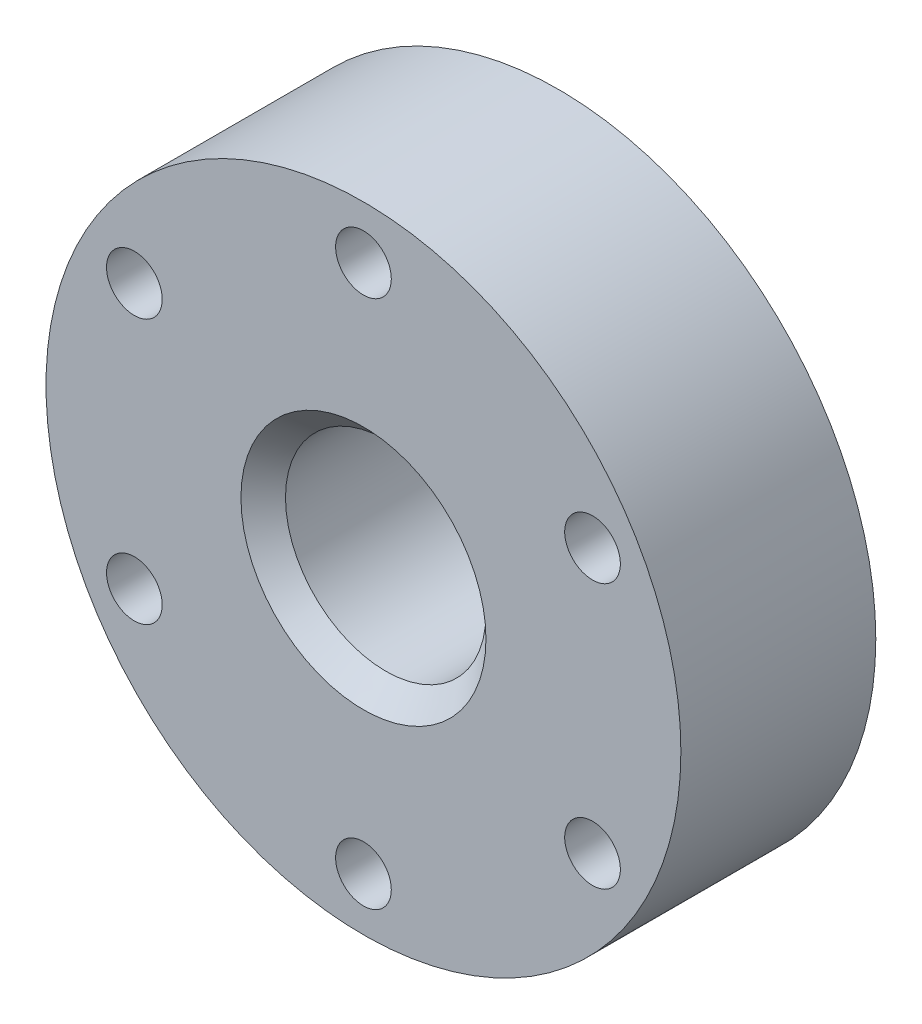
from build123d import *

# Parameters (mm, degrees)
SKETCH1_R           = 28.5
SKETCH1_R_2         = 2.5
BOSS_EXTRUDE1_DEPTH = 17.5
SKETCH2_R           = 9
CUT_EXTRUDE1_DEPTH  = 18.5
CHAMFER1_SIZE       = 2


with BuildPart() as part:
    # Sketch1 → Boss-Extrude1 (new body)
    with BuildSketch(Plane.XY):
        Circle(SKETCH1_R)
        with Locations((0, 23.75)):
            Circle(SKETCH1_R_2, mode=Mode.SUBTRACT)
        with Locations((20.56810334, 11.875)):
            Circle(SKETCH1_R_2, mode=Mode.SUBTRACT)
        with Locations((20.56810334, -11.875)):
            Circle(SKETCH1_R_2, mode=Mode.SUBTRACT)
        with Locations((0, -23.75)):
            Circle(SKETCH1_R_2, mode=Mode.SUBTRACT)
        with Locations((-20.56810334, -11.875)):
            Circle(SKETCH1_R_2, mode=Mode.SUBTRACT)
        with Locations((-20.56810334, 11.875)):
            Circle(SKETCH1_R_2, mode=Mode.SUBTRACT)
    extrude(amount=BOSS_EXTRUDE1_DEPTH)

    # Sketch2 → Cut-Extrude1 (cut, through all)
    with BuildSketch(Plane.XY.offset(17.5)):
        Circle(SKETCH2_R)
    extrude(amount=-CUT_EXTRUDE1_DEPTH, mode=Mode.SUBTRACT)

    # Chamfer1
    chamfer1_edges = [part.edges().sort_by_distance(p)[0] for p in [
        (-9, 0, 0),
        (-9, 0, 17.5),
    ]]
    chamfer(chamfer1_edges, length=CHAMFER1_SIZE)


solid = part.part
